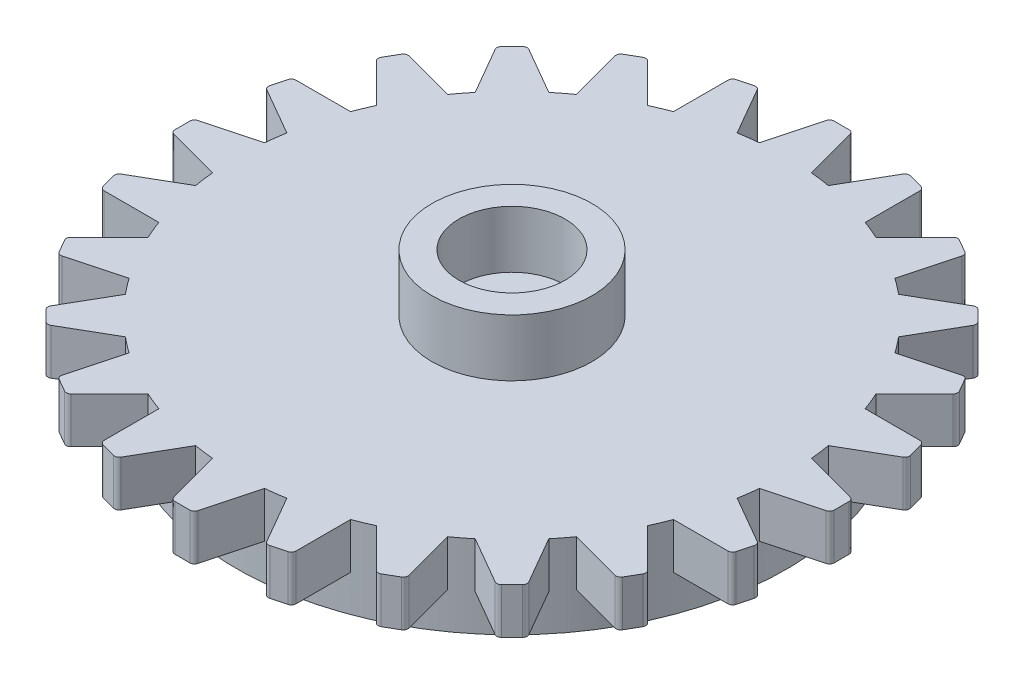
from build123d import *

# Parameters (mm, degrees)
SKETCH1_R                = 15
BOSS_EXTRUDE1_DEPTH      = 2.5
SKETCH2_R                = 4.37
SKETCH2_R_2              = 2.9
BOSS_EXTRUDE2_DEPTH      = 3.12
BOSS_EXTRUDE3_DEPTH      = 2.5
FILLET1_R                = 0.25
CIRPATTERN1_COUNT        = 24
FILLET1_OF_CIRPATTERN1_R = 0.25
SKETCH4_R                = 15
SKETCH4_R_2              = 12
BOSS_EXTRUDE4_DEPTH      = 2


with BuildPart() as part:
    # Sketch1 → Boss-Extrude1 (new body)
    with BuildSketch(Plane(origin=(0, 0, 0), x_dir=(1, 0, 0), z_dir=(0, 1, 0))):
        Circle(SKETCH1_R)
    extrude(amount=BOSS_EXTRUDE1_DEPTH)

    # Sketch2 → Boss-Extrude2 (add)
    with BuildSketch(Plane(origin=(0, 2.5, 0), x_dir=(1, 0, 0), z_dir=(0, 1, 0))):
        Circle(SKETCH2_R)
        Circle(SKETCH2_R_2, mode=Mode.SUBTRACT)
    extrude(amount=BOSS_EXTRUDE2_DEPTH)

    # Sketch3 → Boss-Extrude3 (add)
    with BuildSketch(Plane.XZ):
        Polygon((0, 18), (0.6, 18), (1.564617093, 14.4), (-1.564617093, 14.4), (-0.6, 18), align=None)
    boss_extrude3 = extrude(amount=-BOSS_EXTRUDE3_DEPTH)

    # Fillet1
    fillet1_edges = [part.edges().sort_by_distance(p)[0] for p in [
        (0.6, 1.25, 18),
        (-0.6, 1.25, 18),
    ]]
    fillet(fillet1_edges, radius=FILLET1_R)

    # CirPattern1: Boss-Extrude3 ×24 about axis
    cirpattern1_axis = Axis((0, 0, 0), (0, 1, 0))
    for i in range(1, CIRPATTERN1_COUNT):
        add(boss_extrude3.rotate(cirpattern1_axis, i * 360 / CIRPATTERN1_COUNT))

    # Fillet1 of CirPattern1
    fillet1_of_cirpattern1_edges = [part.edges().sort_by_distance(p)[0] for p in [
        (5.238298308, 1.25, 17.231373446),
        (4.079187316, 1.25, 17.5419563),
        (9.519615242, 1.25, 15.288457268),
        (8.480384758, 1.25, 15.888457268),
        (13.15218613, 1.25, 12.303657993),
        (12.303657993, 1.25, 13.15218613),
        (15.888457268, 1.25, 8.480384758),
        (15.288457268, 1.25, 9.519615242),
        (17.5419563, 1.25, 4.079187316),
        (17.231373446, 1.25, 5.238298308),
        (18, 1.25, -0.6),
        (18, 1.25, 0.6),
        (17.231373446, 1.25, -5.238298308),
        (17.5419563, 1.25, -4.079187316),
        (15.288457268, 1.25, -9.519615242),
        (15.888457268, 1.25, -8.480384758),
        (12.303657993, 1.25, -13.15218613),
        (13.15218613, 1.25, -12.303657993),
        (8.480384758, 1.25, -15.888457268),
        (9.519615242, 1.25, -15.288457268),
        (4.079187316, 1.25, -17.5419563),
        (5.238298308, 1.25, -17.231373446),
        (-0.6, 1.25, -18),
        (0.6, 1.25, -18),
        (-5.238298308, 1.25, -17.231373446),
        (-4.079187316, 1.25, -17.5419563),
        (-9.519615242, 1.25, -15.288457268),
        (-8.480384758, 1.25, -15.888457268),
        (-13.15218613, 1.25, -12.303657993),
        (-12.303657993, 1.25, -13.15218613),
        (-15.888457268, 1.25, -8.480384758),
        (-15.288457268, 1.25, -9.519615242),
        (-17.5419563, 1.25, -4.079187316),
        (-17.231373446, 1.25, -5.238298308),
        (-18, 1.25, 0.6),
        (-18, 1.25, -0.6),
        (-17.231373446, 1.25, 5.238298308),
        (-17.5419563, 1.25, 4.079187316),
        (-15.288457268, 1.25, 9.519615242),
        (-15.888457268, 1.25, 8.480384758),
        (-12.303657993, 1.25, 13.15218613),
        (-13.15218613, 1.25, 12.303657993),
        (-8.480384758, 1.25, 15.888457268),
        (-9.519615242, 1.25, 15.288457268),
        (-4.079187316, 1.25, 17.5419563),
        (-5.238298308, 1.25, 17.231373446),
    ]]
    fillet(fillet1_of_cirpattern1_edges, radius=FILLET1_OF_CIRPATTERN1_R)

    # Sketch4 → Boss-Extrude4 (add)
    with BuildSketch(Plane.XZ):
        Circle(SKETCH4_R)
        Circle(SKETCH4_R_2, mode=Mode.SUBTRACT)
    extrude(amount=BOSS_EXTRUDE4_DEPTH)


solid = part.part
